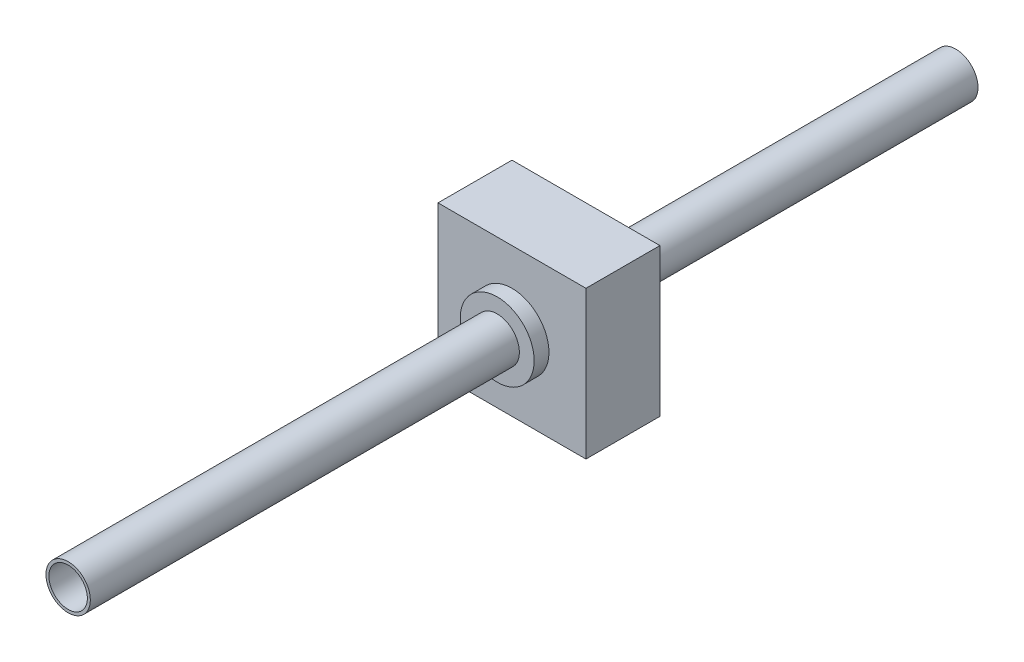
from build123d import *

# Parameters (mm, degrees)
SKETCH1_W           = 1000
SKETCH1_H           = 1000
SKETCH1_R           = 250
BOSS_EXTRUDE1_DEPTH = 500
SKETCH4_R           = 150
SKETCH4_R_2         = 130
SKETCH8_R           = 250
SKETCH8_R_2         = 150
BOSS_EXTRUDE3_DEPTH = 700


with BuildPart() as part:
    # Sketch1 → Boss-Extrude1 (new body)
    with BuildSketch(Plane.XY):
        Rectangle(SKETCH1_W, SKETCH1_H)
        Circle(SKETCH1_R, mode=Mode.SUBTRACT)
    extrude(amount=-BOSS_EXTRUDE1_DEPTH)


with BuildPart() as body_2:
    # Sweep-Thin3: sweep along a path in Sketch6
    with BuildLine(Plane(origin=(0, 0, 0), x_dir=(1, 0, 0), z_dir=(0, 1, 0))) as sweep_thin3_path:
        Line((0, -3000), (0, 3000))
    # Sketch4 → Sweep-Thin3 (sweep)
    with BuildSketch(Plane.XY.offset(3000)):
        Circle(SKETCH4_R)
        Circle(SKETCH4_R_2, mode=Mode.SUBTRACT)
    sweep(path=sweep_thin3_path.line)


with BuildPart() as body_3:
    # Sketch8 → Boss-Extrude3 (new body)
    with BuildSketch(Plane.XY.offset(100)):
        Circle(SKETCH8_R)
        Circle(SKETCH8_R_2, mode=Mode.SUBTRACT)
    extrude(amount=-BOSS_EXTRUDE3_DEPTH)


solid = Compound([part.part, body_2.part, body_3.part])
